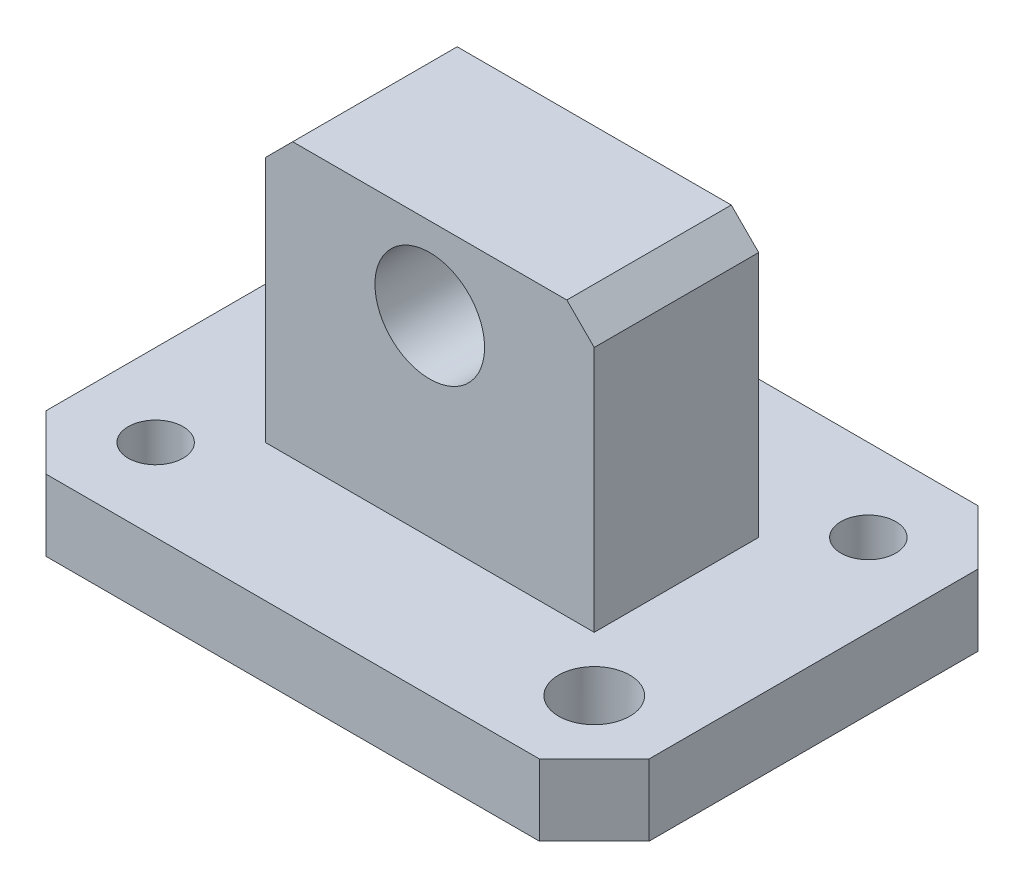
from build123d import *

# Parameters (mm, degrees)
EXTRUDE_1_DEPTH     = 13
SKETCH_3_W          = 60
SKETCH_3_H          = 30
EXTRUDE_2_DEPTH     = 50
CHAMFER_1_SIZE      = 5
SKETCH_4_R          = 6.5
SKETCH_4_R_2        = 5
CUT_EXTRUDE_1_DEPTH = 50
SKETCH_5_R          = 10
CUT_EXTRUDE_2_DEPTH = 50


with BuildPart() as part:
    # Эскиз1 → Бобышка-Вытянуть1 (new body)
    with BuildSketch(Plane(origin=(0, 0, 0), x_dir=(1, 0, 0), z_dir=(0, 1, 0))):
        Polygon((0, 70), (10, 80), (100, 80), (110, 70), (110, 10), (100, 0), (10, 0), (0, 10), align=None)
    extrude(amount=EXTRUDE_1_DEPTH)

    # Эскиз3 → Бобышка-Вытянуть2 (add)
    with BuildSketch(Plane(origin=(0, 13, 0), x_dir=(1, 0, 0), z_dir=(0, 1, 0))):
        with Locations((55, 40)):
            Rectangle(SKETCH_3_W, SKETCH_3_H)
    extrude(amount=EXTRUDE_2_DEPTH)

    # Фаска1
    chamfer_1_edges = [part.edges().sort_by_distance(p)[0] for p in [
        (25, 63, -40),
        (85, 63, -40),
    ]]
    chamfer(chamfer_1_edges, length=CHAMFER_1_SIZE)

    # Эскиз4 → Вырез-Вытянуть1 (cut)
    with BuildSketch(Plane(origin=(0, 13, 0), x_dir=(1, 0, 0), z_dir=(0, 1, 0))):
        with Locations((15, 65)):
            Circle(SKETCH_4_R)
        with Locations((95, 15)):
            Circle(SKETCH_4_R)
        with Locations((95, 65)):
            Circle(SKETCH_4_R_2)
        with Locations((15, 15)):
            Circle(SKETCH_4_R_2)
    extrude(amount=-CUT_EXTRUDE_1_DEPTH, mode=Mode.SUBTRACT)

    # Эскиз5 → Вырез-Вытянуть2 (cut)
    with BuildSketch(Plane.XY.offset(-25)):
        with Locations((55, 48)):
            Circle(SKETCH_5_R)
    extrude(amount=-CUT_EXTRUDE_2_DEPTH, mode=Mode.SUBTRACT)


solid = part.part
